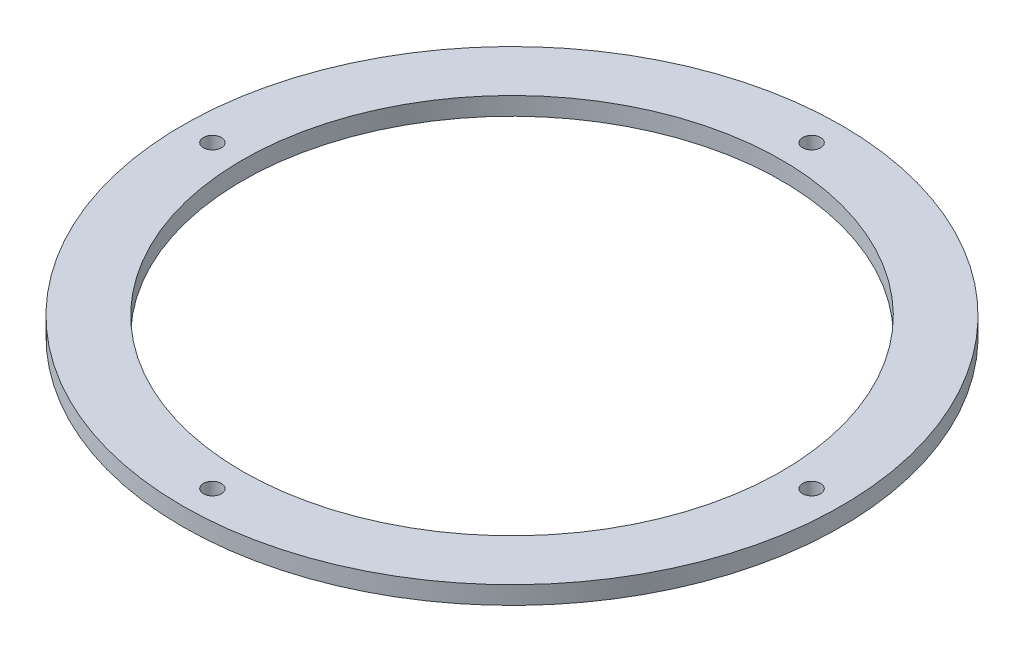
from build123d import *

# Parameters (mm, degrees)
SKETCH1_R           = 55
SKETCH1_R_2         = 45
BOSS_EXTRUDE1_DEPTH = 3
SKETCH2_R           = 1.5
CUT_EXTRUDE1_DEPTH  = 3


with BuildPart() as part:
    # Sketch1 → Boss-Extrude1 (new body)
    with BuildSketch(Plane(origin=(0, 0, 0), x_dir=(1, 0, 0), z_dir=(0, 1, 0))):
        Circle(SKETCH1_R)
        Circle(SKETCH1_R_2, mode=Mode.SUBTRACT)
    extrude(amount=BOSS_EXTRUDE1_DEPTH)

    # Sketch2 → Cut-Extrude1 (cut)
    with BuildSketch(Plane(origin=(0, 3, 0), x_dir=(1, 0, 0), z_dir=(0, 1, 0))):
        with Locations((-50, 0)):
            Circle(SKETCH2_R)
        with Locations((0, -50)):
            Circle(SKETCH2_R)
        with Locations((50, 0)):
            Circle(SKETCH2_R)
        with Locations((0, 50)):
            Circle(SKETCH2_R)
    extrude(amount=-CUT_EXTRUDE1_DEPTH, mode=Mode.SUBTRACT)


solid = part.part
